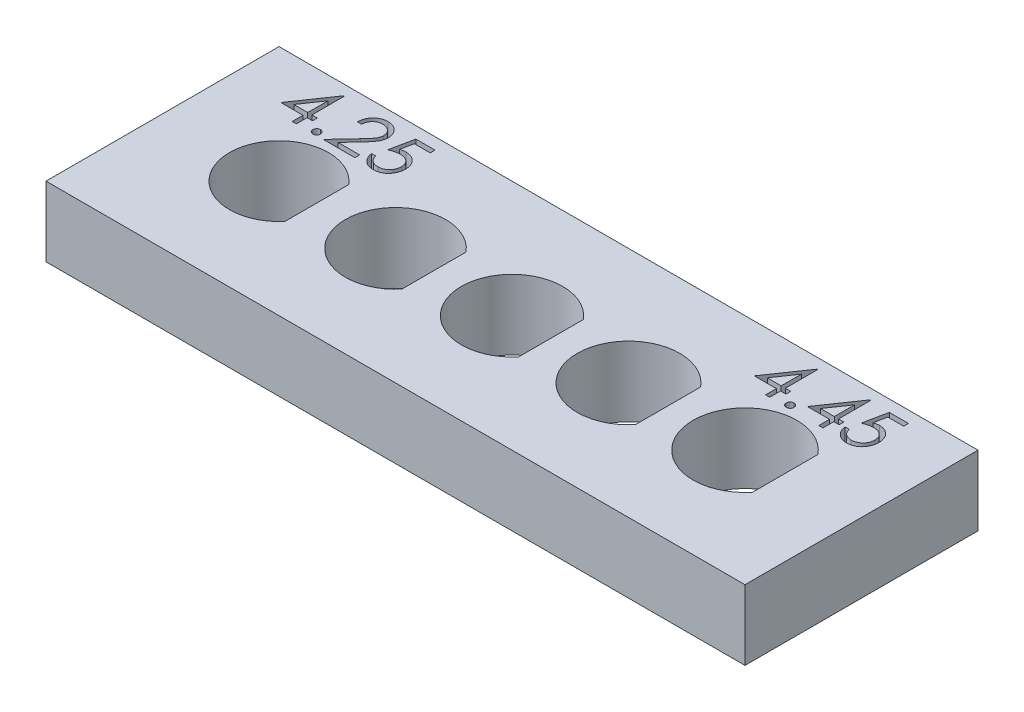
from build123d import *

# Parameters (mm, degrees)
SKETCH1_W           = 30
SKETCH1_H           = 10
BOSS_EXTRUDE1_DEPTH = 3
CUT_EXTRUDE1_DEPTH  = 1


with BuildPart() as part:
    # Sketch1 → Boss-Extrude1 (new body)
    with BuildSketch(Plane(origin=(0, 0, 0), x_dir=(1, 0, 0), z_dir=(0, 1, 0))):
        Rectangle(SKETCH1_W, SKETCH1_H)
        with BuildLine():
            ThreePointArc((11.725, 1.405346932), (7.775, 0), (11.725, -1.405346932))
            Line((11.725, -1.405346932), (11.725, 1.405346932))
        make_face(mode=Mode.SUBTRACT)
        with BuildLine():
            ThreePointArc((6.7, 1.396424004), (2.8, 0), (6.7, -1.396424004))
            Line((6.7, -1.396424004), (6.7, 1.396424004))
        make_face(mode=Mode.SUBTRACT)
        with BuildLine():
            ThreePointArc((1.675, 1.387443693), (-2.175, 0), (1.675, -1.387443693))
            Line((1.675, -1.387443693), (1.675, 1.387443693))
        make_face(mode=Mode.SUBTRACT)
        with BuildLine():
            ThreePointArc((-3.35, 1.378404875), (-7.15, 0), (-3.35, -1.378404875))
            Line((-3.35, -1.378404875), (-3.35, 1.378404875))
        make_face(mode=Mode.SUBTRACT)
        with BuildLine():
            ThreePointArc((-8.375, 1.369306394), (-12.125, 0), (-8.375, -1.369306394))
            Line((-8.375, -1.369306394), (-8.375, 1.369306394))
        make_face(mode=Mode.SUBTRACT)
    extrude(amount=-BOSS_EXTRUDE1_DEPTH)

    # Sketch2 → Cut-Extrude1 (cut)
    with BuildSketch(Plane(origin=(0, 0, 0), x_dir=(1, 0, 0), z_dir=(0, 1, 0))):
        Polygon((-11.790356163, 4.551282051), (-11.75389783, 4.551282051), (-11.75389783, 3.166666667), (-11.523128599, 3.166666667), (-11.523128599, 2.961538462), (-11.75389783, 2.961538462), (-11.75389783, 2.5), (-11.933385009, 2.5), (-11.933385009, 2.961538462), (-12.882102958, 2.961538462), align=None)
        Polygon((-11.933385009, 3.166666667), (-11.933385009, 4.03525641), (-12.529538855, 3.166666667), align=None, mode=Mode.SUBTRACT)
        with BuildLine():
            add(Edge.make_bspline(
                [(-11.023128599, 2.807692308), (-11.011991335, 2.807030498), (-10.990158031, 2.805733098), (-10.958592814, 2.796832142), (-10.930024437, 2.781027193), (-10.90457744, 2.759962748), (-10.883602311, 2.734422369), (-10.86723411, 2.70608185), (-10.85841069, 2.674252368), (-10.85712274, 2.652292554), (-10.856461932, 2.641025641)],
                knots=[0, 0, 0, 0, 3.3407e-05, 6.5491e-05, 9.7402e-05, 0.000130694, 0.000163985, 0.000196089, 0.000228173, 0.000261979, 0.000261979, 0.000261979, 0.000261979], degree=3))
            add(Edge.make_bspline(
                [(-10.856461932, 2.641025641), (-10.857145133, 2.630029453), (-10.858492394, 2.60834513), (-10.867213884, 2.576755723), (-10.883727056, 2.548397492), (-10.904432766, 2.522510556), (-10.930030728, 2.501401487), (-10.958660355, 2.485731004), (-10.990083931, 2.47619273), (-11.011978973, 2.474977703), (-11.023128599, 2.474358974)],
                knots=[0, 0, 0, 0, 3.3009e-05, 6.5092e-05, 9.7196e-05, 0.000130798, 0.000164089, 0.000196, 0.000228196, 0.000261604, 0.000261604, 0.000261604, 0.000261604], degree=3))
            add(Edge.make_bspline(
                [(-11.023128599, 2.474358974), (-11.034286259, 2.474955316), (-11.056068935, 2.47611953), (-11.087375217, 2.485926848), (-11.1161792, 2.501254539), (-11.141772178, 2.522549916), (-11.162651304, 2.548264284), (-11.178437237, 2.576951025), (-11.187917322, 2.608254703), (-11.189164107, 2.630011642), (-11.189795266, 2.641025641)],
                knots=[0, 0, 0, 0, 3.3407e-05, 6.522e-05, 9.7483e-05, 0.000130775, 0.000164376, 0.000196287, 0.000228483, 0.000261492, 0.000261492, 0.000261492, 0.000261492], degree=3))
            add(Edge.make_bspline(
                [(-11.189795266, 2.641025641), (-11.189188352, 2.652311001), (-11.188003427, 2.674344281), (-11.178417335, 2.705886628), (-11.162773786, 2.734554308), (-11.141627846, 2.759923782), (-11.116185391, 2.781173669), (-11.087444702, 2.796639265), (-11.055993536, 2.805805215), (-11.034273571, 2.807052367), (-11.023128599, 2.807692308)],
                knots=[0, 0, 0, 0, 3.3806e-05, 6.6002e-05, 9.7913e-05, 0.000131205, 0.000164497, 0.00019676, 0.000228459, 0.000261866, 0.000261866, 0.000261866, 0.000261866], degree=3))
        make_face()
        with BuildLine():
            Line((-10.343641419, 3.884615385), (-10.523128599, 3.884615385))
            add(Edge.make_bspline(
                [(-10.523128599, 3.884615385), (-10.521958797, 3.90842732), (-10.519661338, 3.955193329), (-10.508902315, 4.023378418), (-10.493507528, 4.088552589), (-10.471740983, 4.15019254), (-10.444708824, 4.208843287), (-10.412291666, 4.264271867), (-10.37389518, 4.316266832), (-10.330348475, 4.364346171), (-10.28305211, 4.408453354), (-10.232020144, 4.446542065), (-10.178394414, 4.478723591), (-10.122337615, 4.505627158), (-10.063217293, 4.525821356), (-10.001569946, 4.54080515), (-9.937124725, 4.549820204), (-9.893216141, 4.550789225), (-9.870885009, 4.551282051)],
                knots=[0, 0, 0, 0, 7.1476e-05, 0.000140377, 0.000206746, 0.000272127, 0.000336122, 0.000400231, 0.000464416, 0.000529663, 0.000594588, 0.00065813, 0.000720312, 0.00078196, 0.000844298, 0.000907363, 0.000972068, 0.001039034, 0.001039034, 0.001039034, 0.001039034], degree=3))
            add(Edge.make_bspline(
                [(-9.870885009, 4.551282051), (-9.848954681, 4.550768648), (-9.80586237, 4.549759828), (-9.74296979, 4.541096382), (-9.683097051, 4.527527473), (-9.626361184, 4.508490092), (-9.573214861, 4.482898991), (-9.523258836, 4.45215754), (-9.475898373, 4.416603351), (-9.433265925, 4.374744029), (-9.394118451, 4.330056952), (-9.360345734, 4.282349578), (-9.331423926, 4.233075701), (-9.30731668, 4.181859586), (-9.289570315, 4.128218998), (-9.276097053, 4.072934882), (-9.268481389, 4.01543499), (-9.267312575, 3.976516958), (-9.266718342, 3.956730769)],
                knots=[0, 0, 0, 0, 6.5765e-05, 0.000129226, 0.000190065, 0.000249739, 0.000308338, 0.000366606, 0.000425502, 0.000485572, 0.000545498, 0.000603529, 0.000660629, 0.000716733, 0.000772986, 0.000829833, 0.000887231, 0.000946593, 0.000946593, 0.000946593, 0.000946593], degree=3))
            add(Edge.make_bspline(
                [(-9.266718342, 3.956730769), (-9.267685921, 3.928874864), (-9.269604099, 3.873651885), (-9.286012314, 3.792500534), (-9.311638892, 3.713875723), (-9.342494525, 3.650597265), (-9.373621636, 3.599606697), (-9.40167164, 3.55762458), (-9.434508675, 3.512421455), (-9.472610674, 3.464148691), (-9.515189458, 3.412428174), (-9.562630694, 3.357291148), (-9.615272684, 3.29930728), (-9.652220398, 3.259704079), (-9.671365778, 3.239182692)],
                knots=[0, 0, 0, 0, 8.3496e-05, 0.000165527, 0.000247371, 0.000331052, 0.000375988, 0.000426546, 0.000482483, 0.000543554, 0.00061101, 0.000683451, 0.000761741, 0.000845938, 0.000845938, 0.000845938, 0.000845938], degree=3))
            Line((-9.671365778, 3.239182692), (-10.171766419, 2.705128205))
            Line((-10.171766419, 2.705128205), (-9.241077317, 2.705128205))
            Line((-9.241077317, 2.705128205), (-9.241077317, 2.5))
            Line((-9.241077317, 2.5), (-10.600051676, 2.5))
            Line((-10.600051676, 2.5), (-9.82441065, 3.327724359))
            add(Edge.make_bspline(
                [(-9.82441065, 3.327724359), (-9.805526143, 3.347437677), (-9.769252871, 3.385302926), (-9.717948541, 3.440584618), (-9.671869119, 3.49187007), (-9.630716323, 3.539062383), (-9.595382892, 3.582851851), (-9.564027331, 3.621820253), (-9.538904136, 3.657679939), (-9.511638195, 3.699246004), (-9.485230206, 3.749995899), (-9.462537431, 3.81201515), (-9.448700375, 3.875859295), (-9.447040469, 3.919003316), (-9.446205522, 3.940705128)],
                knots=[0, 0, 0, 0, 8.1897e-05, 0.000157307, 0.000226246, 0.000288736, 0.000345114, 0.000395046, 0.000438733, 0.000476406, 0.000544141, 0.000609793, 0.000674068, 0.000739121, 0.000739121, 0.000739121, 0.000739121], degree=3))
            add(Edge.make_bspline(
                [(-9.446205522, 3.940705128), (-9.446568803, 3.954351642), (-9.447284761, 3.981246299), (-9.453603445, 4.020678161), (-9.463152306, 4.058715198), (-9.476835311, 4.095474409), (-9.494896305, 4.13058621), (-9.516881093, 4.164093341), (-9.542246844, 4.196487036), (-9.571590426, 4.226860349), (-9.603825581, 4.254678181), (-9.637879437, 4.279320515), (-9.673908068, 4.299914293), (-9.711759567, 4.316796291), (-9.751328407, 4.330039366), (-9.792691118, 4.339215697), (-9.835733413, 4.344977117), (-9.865123982, 4.345756643), (-9.880099753, 4.346153846)],
                knots=[0, 0, 0, 0, 4.0914e-05, 8.0635e-05, 0.000119503, 0.000158423, 0.000198022, 0.000237693, 0.00027849, 0.000321276, 0.000364167, 0.000406083, 0.00044718, 0.000488428, 0.000530237, 0.000572129, 0.000615363, 0.000660279, 0.000660279, 0.000660279, 0.000660279], degree=3))
            add(Edge.make_bspline(
                [(-9.880099753, 4.346153846), (-9.895740229, 4.345745256), (-9.926455541, 4.344942853), (-9.971552131, 4.339329902), (-10.014572575, 4.329646565), (-10.055625091, 4.316402751), (-10.09477914, 4.299569295), (-10.131844308, 4.278602583), (-10.166737388, 4.253583444), (-10.199523973, 4.225217412), (-10.229731961, 4.193635926), (-10.256273033, 4.158430233), (-10.279463898, 4.120243138), (-10.299697746, 4.079177681), (-10.316129568, 4.034861235), (-10.328685654, 3.987451118), (-10.338620995, 3.937153186), (-10.34194015, 3.902418851), (-10.343641419, 3.884615385)],
                knots=[0, 0, 0, 0, 4.6918e-05, 9.2139e-05, 0.000136072, 0.000179023, 0.000221372, 0.000263711, 0.000306512, 0.000349969, 0.000393611, 0.000437362, 0.000481955, 0.000527466, 0.000574499, 0.000623482, 0.000674477, 0.0007281, 0.0007281, 0.0007281, 0.0007281], degree=3))
        make_face()
        with BuildLine():
            Line((-7.805179881, 4.5), (-7.805179881, 4.294871795))
            Line((-7.805179881, 4.294871795), (-8.485468342, 4.294871795))
            Line((-8.485468342, 4.294871795), (-8.593240778, 3.768830128))
            add(Edge.make_bspline(
                [(-8.593240778, 3.768830128), (-8.572065993, 3.774675998), (-8.531043195, 3.786001446), (-8.470494703, 3.798576172), (-8.413013444, 3.806156425), (-8.375713233, 3.80719146), (-8.357663855, 3.807692308)],
                knots=[0, 0, 0, 0, 6.5887e-05, 0.000127645, 0.000185389, 0.000239529, 0.000239529, 0.000239529, 0.000239529], degree=3))
            add(Edge.make_bspline(
                [(-8.357663855, 3.807692308), (-8.33533029, 3.807208916), (-8.29141692, 3.806258447), (-8.227166093, 3.797131676), (-8.165833011, 3.78276601), (-8.107545943, 3.762697141), (-8.052197056, 3.737034436), (-8.000295593, 3.704977327), (-7.9510625, 3.667529709), (-7.905381017, 3.624475417), (-7.863938556, 3.577091636), (-7.827500847, 3.526144281), (-7.796550796, 3.472128474), (-7.771658936, 3.414528126), (-7.751782173, 3.353980038), (-7.738552462, 3.289847134), (-7.729742914, 3.222733923), (-7.728758693, 3.176845597), (-7.728256804, 3.153445513)],
                knots=[0, 0, 0, 0, 6.6966e-05, 0.000131671, 0.000194254, 0.000255703, 0.000316285, 0.000376889, 0.000438349, 0.000501556, 0.000564873, 0.000626909, 0.000689175, 0.000751253, 0.000814855, 0.000879997, 0.000947431, 0.001017599, 0.001017599, 0.001017599, 0.001017599], degree=3))
            add(Edge.make_bspline(
                [(-7.728256804, 3.153445513), (-7.728636847, 3.137147101), (-7.729391797, 3.104770537), (-7.73323099, 3.056688136), (-7.740622828, 3.00962366), (-7.750547242, 2.963570865), (-7.763428623, 2.918616938), (-7.779022368, 2.874633208), (-7.798105813, 2.831893433), (-7.819038027, 2.789993207), (-7.842607443, 2.749879774), (-7.86876659, 2.712366068), (-7.896404014, 2.676889335), (-7.926141948, 2.643830059), (-7.958256803, 2.613405478), (-7.992359641, 2.585435031), (-8.028178337, 2.559445699), (-8.066267047, 2.536492445), (-8.105777038, 2.515370756), (-8.147278876, 2.49804302), (-8.189827848, 2.48255129), (-8.234036348, 2.470202988), (-8.279804241, 2.460527243), (-8.32720697, 2.453955471), (-8.375995924, 2.449168936), (-8.40906736, 2.448869303), (-8.42577283, 2.448717949)],
                knots=[0, 0, 0, 0, 4.8904e-05, 9.7148e-05, 0.000144575, 0.000191724, 0.000238392, 0.000284773, 0.000331595, 0.000378717, 0.000425235, 0.000471022, 0.000515824, 0.000560076, 0.000604285, 0.000648401, 0.00069232, 0.000736914, 0.000781716, 0.000826589, 0.000871704, 0.000917491, 0.000964165, 0.001011929, 0.001061005, 0.0011111, 0.0011111, 0.0011111, 0.0011111], degree=3))
            add(Edge.make_bspline(
                [(-8.42577283, 2.448717949), (-8.445700933, 2.449112713), (-8.484907122, 2.449889366), (-8.542347446, 2.458014215), (-8.597612935, 2.469650738), (-8.650258707, 2.487157178), (-8.700756572, 2.509092775), (-8.748426696, 2.536816302), (-8.79448714, 2.568232932), (-8.837065447, 2.60530742), (-8.876583226, 2.645830667), (-8.911958374, 2.689806462), (-8.943463275, 2.736509), (-8.970593416, 2.786165088), (-8.993735142, 2.838644249), (-9.011915136, 2.894143106), (-9.026588481, 2.95237168), (-9.03279615, 2.9924594), (-9.035949112, 3.012820513)],
                knots=[0, 0, 0, 0, 5.9744e-05, 0.000117539, 0.000173727, 0.000228967, 0.00028368, 0.000338591, 0.000394159, 0.000450695, 0.000507644, 0.000563769, 0.000619773, 0.000676432, 0.000733302, 0.000791581, 0.000851438, 0.00091322, 0.00091322, 0.00091322, 0.00091322], degree=3))
            Line((-9.035949112, 3.012820513), (-8.856461932, 3.012820513))
            add(Edge.make_bspline(
                [(-8.856461932, 3.012820513), (-8.852045614, 2.993748254), (-8.843557204, 2.957090314), (-8.824925348, 2.905586691), (-8.802144848, 2.859689991), (-8.775056649, 2.818793087), (-8.742742345, 2.783130803), (-8.705868386, 2.751349624), (-8.66452683, 2.722678122), (-8.618587842, 2.698779398), (-8.570123225, 2.678397253), (-8.519399105, 2.664824856), (-8.467796621, 2.655281489), (-8.432894695, 2.654326197), (-8.415356163, 2.653846154)],
                knots=[0, 0, 0, 0, 5.8691e-05, 0.000112807, 0.000163871, 0.000212096, 0.000259475, 0.000307756, 0.000357876, 0.00041003, 0.000462854, 0.000515246, 0.00056728, 0.000619839, 0.000619839, 0.000619839, 0.000619839], degree=3))
            add(Edge.make_bspline(
                [(-8.415356163, 2.653846154), (-8.398237052, 2.65431517), (-8.364529382, 2.655238666), (-8.314922875, 2.662346673), (-8.267029804, 2.673293857), (-8.221322743, 2.689676631), (-8.177001864, 2.709587898), (-8.135188281, 2.73513937), (-8.094672351, 2.764545095), (-8.056713417, 2.798234598), (-8.021948018, 2.835360138), (-7.991230234, 2.875061506), (-7.965643427, 2.917413989), (-7.944081079, 2.961684362), (-7.927707765, 3.008357824), (-7.916027204, 3.057215638), (-7.909168314, 3.108378484), (-7.908224782, 3.143275232), (-7.907743984, 3.161057692)],
                knots=[0, 0, 0, 0, 5.1338e-05, 0.000101086, 0.000150064, 0.000198467, 0.000246512, 0.000295571, 0.000345174, 0.000396545, 0.000447567, 0.00049757, 0.000546836, 0.000595755, 0.000645047, 0.000694897, 0.000746233, 0.000799572, 0.000799572, 0.000799572, 0.000799572], degree=3))
            add(Edge.make_bspline(
                [(-7.907743984, 3.161057692), (-7.908120258, 3.177100979), (-7.90885676, 3.20850343), (-7.914874229, 3.254445834), (-7.92534107, 3.297916143), (-7.939869002, 3.339124277), (-7.958314435, 3.378109101), (-7.980855185, 3.41491085), (-8.007914269, 3.449044469), (-8.03882392, 3.480525928), (-8.072685657, 3.509580142), (-8.110082082, 3.534348192), (-8.150230611, 3.555184716), (-8.192647525, 3.57316643), (-8.238341753, 3.586081141), (-8.2864084, 3.595777076), (-8.337366519, 3.601385854), (-8.372206912, 3.602164076), (-8.390115778, 3.602564103)],
                knots=[0, 0, 0, 0, 4.8119e-05, 9.4185e-05, 0.000138691, 0.000182027, 0.000225037, 0.000267846, 0.000311208, 0.000355406, 0.000400035, 0.000444816, 0.000489618, 0.000535599, 0.000582763, 0.000631792, 0.000682583, 0.000736306, 0.000736306, 0.000736306, 0.000736306], degree=3))
            add(Edge.make_bspline(
                [(-8.390115778, 3.602564103), (-8.405618023, 3.602232336), (-8.437626226, 3.601547323), (-8.486724985, 3.59650361), (-8.538320255, 3.588366871), (-8.592214252, 3.577174729), (-8.648568828, 3.5625284), (-8.707265057, 3.544977256), (-8.768426353, 3.523993257), (-8.809636481, 3.508146278), (-8.830820907, 3.5)],
                knots=[0, 0, 0, 0, 4.6502e-05, 9.6015e-05, 0.000147919, 0.000203157, 0.000261071, 0.000322547, 0.000386909, 0.000454996, 0.000454996, 0.000454996, 0.000454996], degree=3))
            Line((-8.830820907, 3.5), (-8.625692701, 4.5))
            Line((-8.625692701, 4.5), (-7.805179881, 4.5))
        make_face()
        Polygon((8.528251812, 4.551282051), (8.564710145, 4.551282051), (8.564710145, 3.166666667), (8.795479376, 3.166666667), (8.795479376, 2.961538462), (8.564710145, 2.961538462), (8.564710145, 2.5), (8.385222966, 2.5), (8.385222966, 2.961538462), (7.436505017, 2.961538462), align=None)
        Polygon((8.385222966, 3.166666667), (8.385222966, 4.03525641), (7.78906912, 3.166666667), align=None, mode=Mode.SUBTRACT)
        with BuildLine():
            add(Edge.make_bspline(
                [(9.295479376, 2.807692308), (9.30661664, 2.807030498), (9.328449945, 2.805733098), (9.360015161, 2.796832142), (9.388583538, 2.781027193), (9.414030535, 2.759962748), (9.435005664, 2.734422369), (9.451373865, 2.70608185), (9.460197285, 2.674252368), (9.461485235, 2.652292554), (9.462146043, 2.641025641)],
                knots=[0, 0, 0, 0, 3.3407e-05, 6.5491e-05, 9.7402e-05, 0.000130694, 0.000163985, 0.000196089, 0.000228173, 0.000261979, 0.000261979, 0.000261979, 0.000261979], degree=3))
            add(Edge.make_bspline(
                [(9.462146043, 2.641025641), (9.461462842, 2.630029453), (9.460115581, 2.60834513), (9.451394091, 2.576755723), (9.434880919, 2.548397492), (9.414175209, 2.522510556), (9.388577247, 2.501401487), (9.359947621, 2.485731004), (9.328524044, 2.47619273), (9.306629002, 2.474977703), (9.295479376, 2.474358974)],
                knots=[0, 0, 0, 0, 3.3009e-05, 6.5092e-05, 9.7196e-05, 0.000130798, 0.000164089, 0.000196, 0.000228196, 0.000261604, 0.000261604, 0.000261604, 0.000261604], degree=3))
            add(Edge.make_bspline(
                [(9.295479376, 2.474358974), (9.284321716, 2.474955316), (9.26253904, 2.47611953), (9.231232758, 2.485926848), (9.202428776, 2.501254539), (9.176835797, 2.522549916), (9.155956671, 2.548264284), (9.140170738, 2.576951025), (9.130690653, 2.608254703), (9.129443868, 2.630011642), (9.12881271, 2.641025641)],
                knots=[0, 0, 0, 0, 3.3407e-05, 6.522e-05, 9.7483e-05, 0.000130775, 0.000164376, 0.000196287, 0.000228483, 0.000261492, 0.000261492, 0.000261492, 0.000261492], degree=3))
            add(Edge.make_bspline(
                [(9.12881271, 2.641025641), (9.129419623, 2.652311001), (9.130604548, 2.674344281), (9.14019064, 2.705886628), (9.155834189, 2.734554308), (9.176980129, 2.759923782), (9.202422584, 2.781173669), (9.231163273, 2.796639265), (9.262614439, 2.805805215), (9.284334404, 2.807052367), (9.295479376, 2.807692308)],
                knots=[0, 0, 0, 0, 3.3806e-05, 6.6002e-05, 9.7913e-05, 0.000131205, 0.000164497, 0.00019676, 0.000228459, 0.000261866, 0.000261866, 0.000261866, 0.000261866], degree=3))
        make_face()
        Polygon((10.810303094, 4.551282051), (10.846761427, 4.551282051), (10.846761427, 3.166666667), (11.077530658, 3.166666667), (11.077530658, 2.961538462), (10.846761427, 2.961538462), (10.846761427, 2.5), (10.667274248, 2.5), (10.667274248, 2.961538462), (9.718556299, 2.961538462), align=None)
        Polygon((10.667274248, 3.166666667), (10.667274248, 4.03525641), (10.071120402, 3.166666667), align=None, mode=Mode.SUBTRACT)
        with BuildLine():
            Line((12.513428094, 4.5), (12.513428094, 4.294871795))
            Line((12.513428094, 4.294871795), (11.833139633, 4.294871795))
            Line((11.833139633, 4.294871795), (11.725367197, 3.768830128))
            add(Edge.make_bspline(
                [(11.725367197, 3.768830128), (11.746541982, 3.774675998), (11.78756478, 3.786001446), (11.848113272, 3.798576172), (11.905594531, 3.806156425), (11.942894742, 3.80719146), (11.96094412, 3.807692308)],
                knots=[0, 0, 0, 0, 6.5887e-05, 0.000127645, 0.000185389, 0.000239529, 0.000239529, 0.000239529, 0.000239529], degree=3))
            add(Edge.make_bspline(
                [(11.96094412, 3.807692308), (11.983277685, 3.807208916), (12.027191055, 3.806258447), (12.091441882, 3.797131676), (12.152774964, 3.78276601), (12.211062033, 3.762697141), (12.266410919, 3.737034436), (12.318312382, 3.704977327), (12.367545476, 3.667529709), (12.413226958, 3.624475417), (12.45466942, 3.577091636), (12.491107128, 3.526144281), (12.52205718, 3.472128474), (12.546949039, 3.414528126), (12.566825802, 3.353980038), (12.580055513, 3.289847134), (12.588865061, 3.222733923), (12.589849282, 3.176845597), (12.590351171, 3.153445513)],
                knots=[0, 0, 0, 0, 6.6966e-05, 0.000131671, 0.000194254, 0.000255703, 0.000316285, 0.000376889, 0.000438349, 0.000501556, 0.000564873, 0.000626909, 0.000689175, 0.000751253, 0.000814855, 0.000879997, 0.000947431, 0.001017599, 0.001017599, 0.001017599, 0.001017599], degree=3))
            add(Edge.make_bspline(
                [(12.590351171, 3.153445513), (12.589971128, 3.137147101), (12.589216178, 3.104770537), (12.585376985, 3.056688136), (12.577985147, 3.00962366), (12.568060734, 2.963570865), (12.555179352, 2.918616938), (12.539585607, 2.874633208), (12.520502162, 2.831893433), (12.499569948, 2.789993207), (12.476000532, 2.749879774), (12.449841385, 2.712366068), (12.422203961, 2.676889335), (12.392466027, 2.643830059), (12.360351172, 2.613405478), (12.326248334, 2.585435031), (12.290429638, 2.559445699), (12.252340928, 2.536492445), (12.212830938, 2.515370756), (12.171329099, 2.49804302), (12.128780127, 2.48255129), (12.084571627, 2.470202988), (12.038803734, 2.460527243), (11.991401005, 2.453955471), (11.942612051, 2.449168936), (11.909540615, 2.448869303), (11.892835145, 2.448717949)],
                knots=[0, 0, 0, 0, 4.8904e-05, 9.7148e-05, 0.000144575, 0.000191724, 0.000238392, 0.000284773, 0.000331595, 0.000378717, 0.000425235, 0.000471022, 0.000515824, 0.000560076, 0.000604285, 0.000648401, 0.00069232, 0.000736914, 0.000781716, 0.000826589, 0.000871704, 0.000917491, 0.000964165, 0.001011929, 0.001061005, 0.0011111, 0.0011111, 0.0011111, 0.0011111], degree=3))
            add(Edge.make_bspline(
                [(11.892835145, 2.448717949), (11.872907042, 2.449112713), (11.833700853, 2.449889366), (11.776260529, 2.458014215), (11.72099504, 2.469650738), (11.668349268, 2.487157178), (11.617851403, 2.509092775), (11.570181279, 2.536816302), (11.524120835, 2.568232932), (11.481542528, 2.60530742), (11.442024749, 2.645830667), (11.406649601, 2.689806462), (11.3751447, 2.736509), (11.348014559, 2.786165088), (11.324872833, 2.838644249), (11.30669284, 2.894143106), (11.292019494, 2.95237168), (11.285811825, 2.9924594), (11.282658863, 3.012820513)],
                knots=[0, 0, 0, 0, 5.9744e-05, 0.000117539, 0.000173727, 0.000228967, 0.00028368, 0.000338591, 0.000394159, 0.000450695, 0.000507644, 0.000563769, 0.000619773, 0.000676432, 0.000733302, 0.000791581, 0.000851438, 0.00091322, 0.00091322, 0.00091322, 0.00091322], degree=3))
            Line((11.282658863, 3.012820513), (11.462146043, 3.012820513))
            add(Edge.make_bspline(
                [(11.462146043, 3.012820513), (11.466562361, 2.993748254), (11.475050771, 2.957090314), (11.493682627, 2.905586691), (11.516463127, 2.859689991), (11.543551327, 2.818793087), (11.57586563, 2.783130803), (11.612739589, 2.751349624), (11.654081145, 2.722678122), (11.700020133, 2.698779398), (11.74848475, 2.678397253), (11.79920887, 2.664824856), (11.850811354, 2.655281489), (11.88571328, 2.654326197), (11.903251812, 2.653846154)],
                knots=[0, 0, 0, 0, 5.8691e-05, 0.000112807, 0.000163871, 0.000212096, 0.000259475, 0.000307756, 0.000357876, 0.00041003, 0.000462854, 0.000515246, 0.00056728, 0.000619839, 0.000619839, 0.000619839, 0.000619839], degree=3))
            add(Edge.make_bspline(
                [(11.903251812, 2.653846154), (11.920370923, 2.65431517), (11.954078593, 2.655238666), (12.0036851, 2.662346673), (12.051578171, 2.673293857), (12.097285232, 2.689676631), (12.141606111, 2.709587898), (12.183419695, 2.73513937), (12.223935624, 2.764545095), (12.261894558, 2.798234598), (12.296659957, 2.835360138), (12.327377741, 2.875061506), (12.352964549, 2.917413989), (12.374526896, 2.961684362), (12.39090021, 3.008357824), (12.402580771, 3.057215638), (12.409439662, 3.108378484), (12.410383193, 3.143275232), (12.410863992, 3.161057692)],
                knots=[0, 0, 0, 0, 5.1338e-05, 0.000101086, 0.000150064, 0.000198467, 0.000246512, 0.000295571, 0.000345174, 0.000396545, 0.000447567, 0.00049757, 0.000546836, 0.000595755, 0.000645047, 0.000694897, 0.000746233, 0.000799572, 0.000799572, 0.000799572, 0.000799572], degree=3))
            add(Edge.make_bspline(
                [(12.410863992, 3.161057692), (12.410487718, 3.177100979), (12.409751215, 3.20850343), (12.403733746, 3.254445834), (12.393266905, 3.297916143), (12.378738973, 3.339124277), (12.36029354, 3.378109101), (12.33775279, 3.41491085), (12.310693706, 3.449044469), (12.279784055, 3.480525928), (12.245922318, 3.509580142), (12.208525893, 3.534348192), (12.168377364, 3.555184716), (12.12596045, 3.57316643), (12.080266222, 3.586081141), (12.032199575, 3.595777076), (11.981241456, 3.601385854), (11.946401063, 3.602164076), (11.928492197, 3.602564103)],
                knots=[0, 0, 0, 0, 4.8119e-05, 9.4185e-05, 0.000138691, 0.000182027, 0.000225037, 0.000267846, 0.000311208, 0.000355406, 0.000400035, 0.000444816, 0.000489618, 0.000535599, 0.000582763, 0.000631792, 0.000682583, 0.000736306, 0.000736306, 0.000736306, 0.000736306], degree=3))
            add(Edge.make_bspline(
                [(11.928492197, 3.602564103), (11.912989952, 3.602232336), (11.880981749, 3.601547323), (11.83188299, 3.59650361), (11.78028772, 3.588366871), (11.726393723, 3.577174729), (11.670039147, 3.5625284), (11.611342918, 3.544977256), (11.550181623, 3.523993257), (11.508971494, 3.508146278), (11.487787068, 3.5)],
                knots=[0, 0, 0, 0, 4.6502e-05, 9.6015e-05, 0.000147919, 0.000203157, 0.000261071, 0.000322547, 0.000386909, 0.000454996, 0.000454996, 0.000454996, 0.000454996], degree=3))
            Line((11.487787068, 3.5), (11.692915274, 4.5))
            Line((11.692915274, 4.5), (12.513428094, 4.5))
        make_face()
    extrude(amount=-CUT_EXTRUDE1_DEPTH, mode=Mode.SUBTRACT)


solid = part.part
